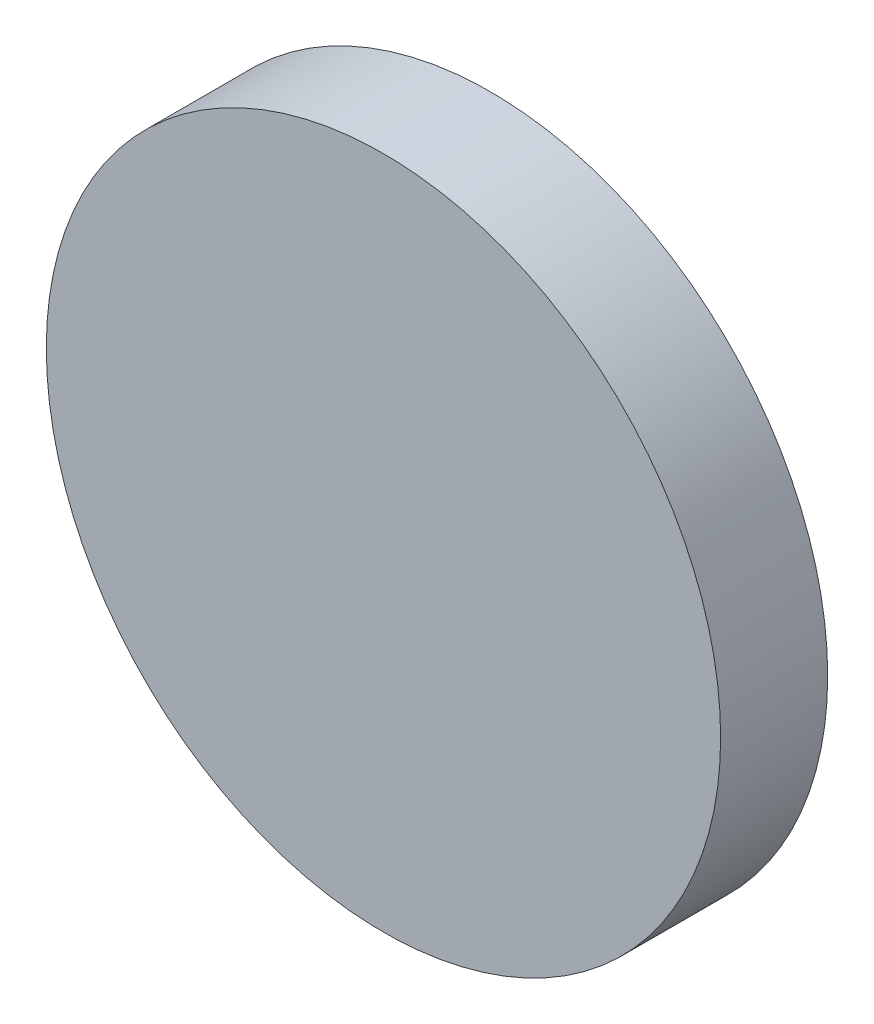
from build123d import *

# Parameters (mm, degrees)
SKETCH1_R           = 5
BOSS_EXTRUDE1_DEPTH = 1.5875


with BuildPart() as part:
    # Sketch1 → Boss-Extrude1 (new body)
    with BuildSketch(Plane.XY):
        Circle(SKETCH1_R)
    extrude(amount=BOSS_EXTRUDE1_DEPTH)


solid = part.part
